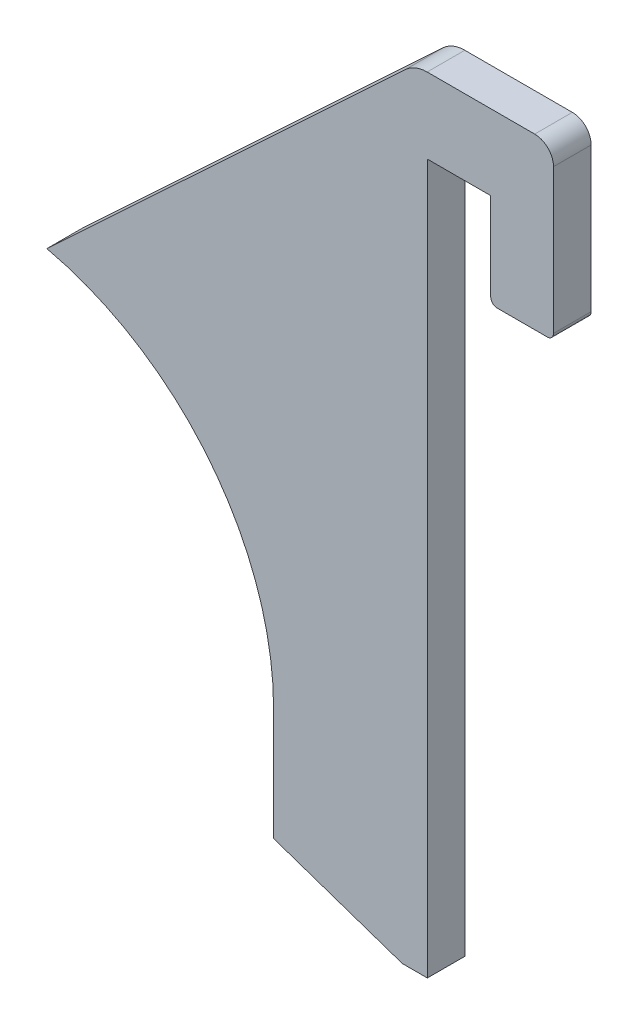
from build123d import *

# Parameters (mm, degrees)
BOSS_EXTRU_1_DEPTH = 6
FILLET1_R          = 5
FILLET1_2_R        = 3
FILLET1_3_R        = 1


with BuildPart() as part:
    # Esquisse1 → Boss.-Extru.1 (new body)
    with BuildSketch(Plane.XY):
        with BuildLine():
            Line((46.5, 0), (46.5, -18))
            Line((46.5, -18), (67, -25))
            Line((67, -25), (71, -25))
            Line((71, -25), (71, 88))
            Line((71, 88), (81.1, 88))
            Line((81.1, 88), (81.1, 73))
            Line((81.1, 73), (91.1, 73))
            Line((91.1, 73), (91.1, 100))
            Line((91.1, 100), (69, 100))
            Line((69, 100), (10.371982926, 45.328489608))
            ThreePointArc((10.371982926, 45.328489608), (36.363080219, 28.982346298), (46.5, 0))
        make_face()
    extrude(amount=BOSS_EXTRU_1_DEPTH)

    # Fillet1
    fillet1_edges = [part.edges().sort_by_distance(p)[0] for p in [
        (69, 100, 3),
    ]]
    fillet(fillet1_edges, radius=FILLET1_R)

    # Fillet1 2
    fillet1_2_edges = [part.edges().sort_by_distance(p)[0] for p in [
        (91.1, 100, 3),
    ]]
    fillet(fillet1_2_edges, radius=FILLET1_2_R)

    # Fillet1 3
    fillet1_3_edges = [part.edges().sort_by_distance(p)[0] for p in [
        (91.1, 73, 3),
        (81.1, 73, 3),
    ]]
    fillet(fillet1_3_edges, radius=FILLET1_3_R)


solid = part.part
